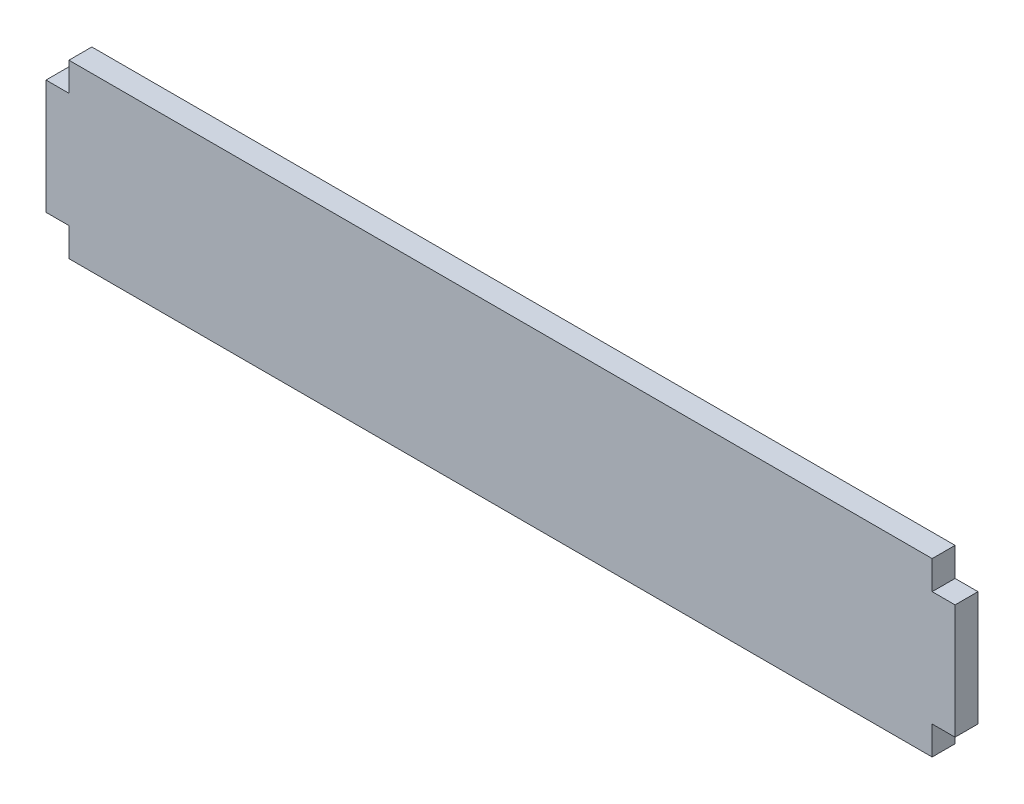
from build123d import *

# Parameters (mm, degrees)
CROQUIS1_W                   = 226
CROQUIS1_H                   = 45
SALIENTE_EXTRUIR1_DEPTH      = 6
CROQUIS2_W                   = 6
CROQUIS2_H                   = 30
SALIENTE_EXTRUIR2_DEPTH      = 6
SALIENTE_EXTRUIR2_DEPTH_BACK = 232


with BuildPart() as part:
    # Croquis1 → Saliente-Extruir1 (new body)
    with BuildSketch(Plane.XY):
        Rectangle(CROQUIS1_W, CROQUIS1_H)
    extrude(amount=SALIENTE_EXTRUIR1_DEPTH)

    # Croquis2 → Saliente-Extruir2 (add, two sides)
    with BuildSketch(Plane.ZY.offset(113)) as saliente_extruir2_sk:
        with Locations((3, 0)):
            Rectangle(CROQUIS2_W, CROQUIS2_H)
    extrude(amount=SALIENTE_EXTRUIR2_DEPTH)
    extrude(saliente_extruir2_sk.sketch, amount=-SALIENTE_EXTRUIR2_DEPTH_BACK)


solid = part.part
